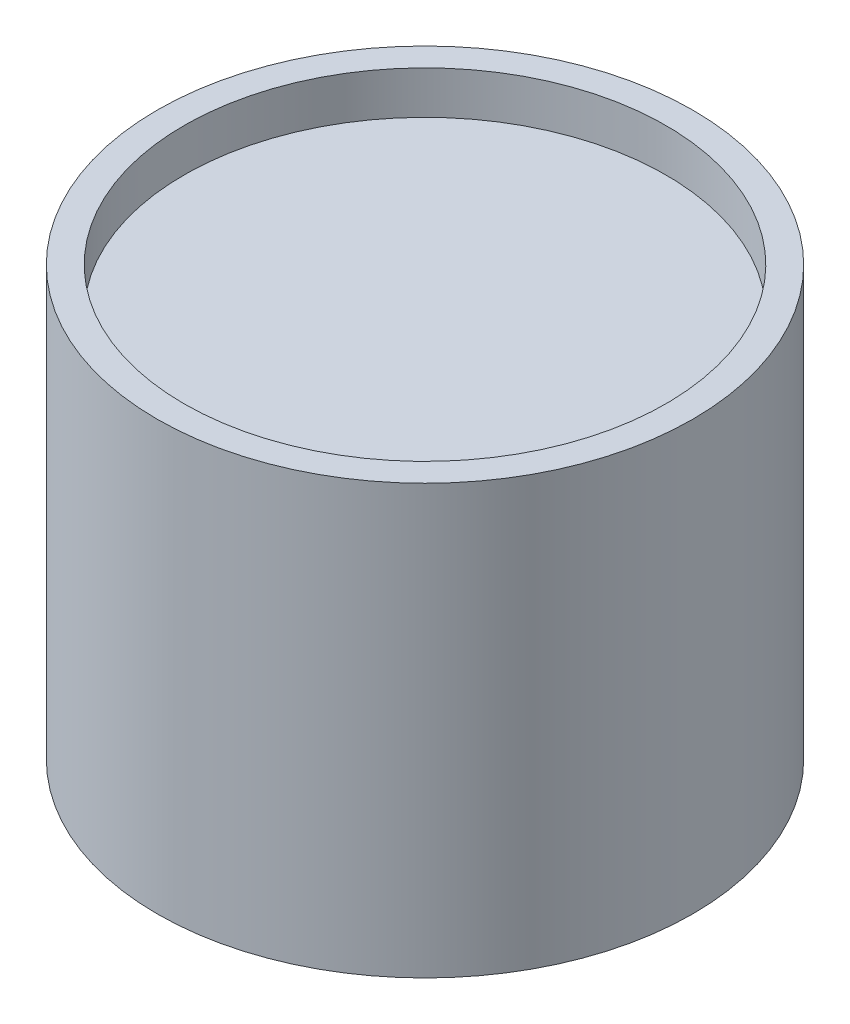
from build123d import *

# Parameters (mm, degrees)
SCHIZZO1_R                   = 5
ESTRUSIONE_ESTRUSIONE1_DEPTH = 8
SCHIZZO2_R                   = 4.5
TAGLIO_ESTRUSIONE1_DEPTH     = 0.8
SCHIZZO3_R                   = 4.5
TAGLIO_ESTRUSIONE2_DEPTH     = 0.8


with BuildPart() as part:
    # Schizzo1 → Estrusione-Estrusione1 (new body)
    with BuildSketch(Plane(origin=(0, 0, 0), x_dir=(1, 0, 0), z_dir=(0, 1, 0))):
        Circle(SCHIZZO1_R)
    extrude(amount=ESTRUSIONE_ESTRUSIONE1_DEPTH)

    # Schizzo2 → Taglio-Estrusione1 (cut)
    with BuildSketch(Plane(origin=(0, 8, 0), x_dir=(1, 0, 0), z_dir=(0, 1, 0))):
        Circle(SCHIZZO2_R)
    extrude(amount=-TAGLIO_ESTRUSIONE1_DEPTH, mode=Mode.SUBTRACT)

    # Schizzo3 → Taglio-Estrusione2 (cut)
    with BuildSketch(Plane.XZ):
        Circle(SCHIZZO3_R)
    extrude(amount=-TAGLIO_ESTRUSIONE2_DEPTH, mode=Mode.SUBTRACT)


solid = part.part
